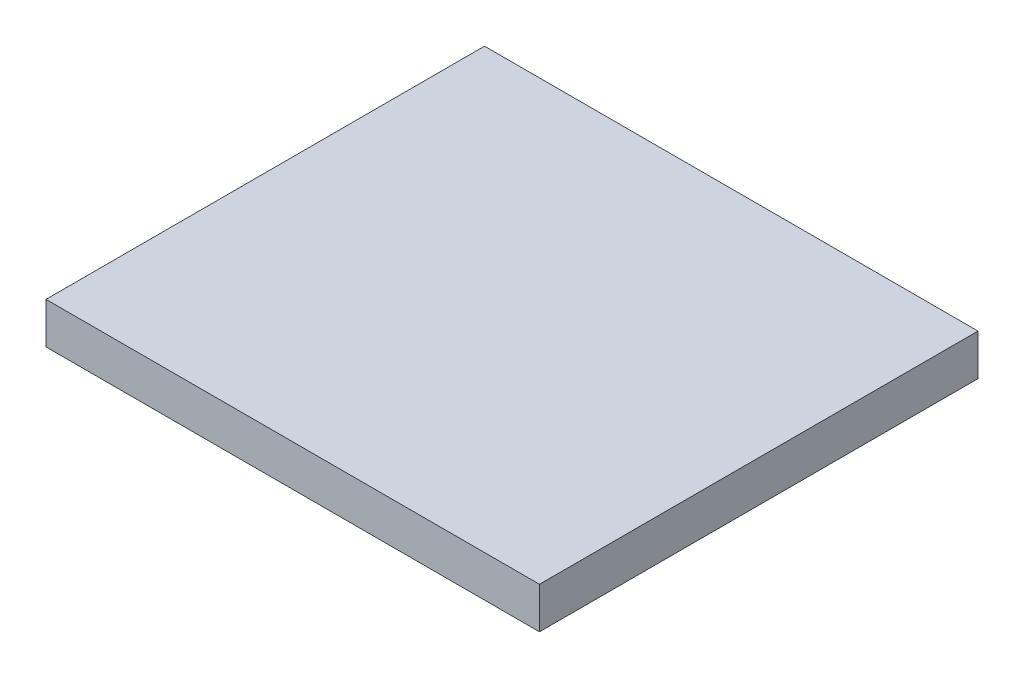
from build123d import *

# Parameters (mm, degrees)
SKETCH1_W           = 5475.224
SKETCH1_H           = 4865.624
BOSS_EXTRUDE1_DEPTH = 457.2


with BuildPart() as part:
    # Sketch1 → Boss-Extrude1 (new body)
    with BuildSketch(Plane(origin=(0, 0, 0), x_dir=(1, 0, 0), z_dir=(0, 1, 0))):
        Rectangle(SKETCH1_W, SKETCH1_H)
    extrude(amount=BOSS_EXTRUDE1_DEPTH)


solid = part.part
